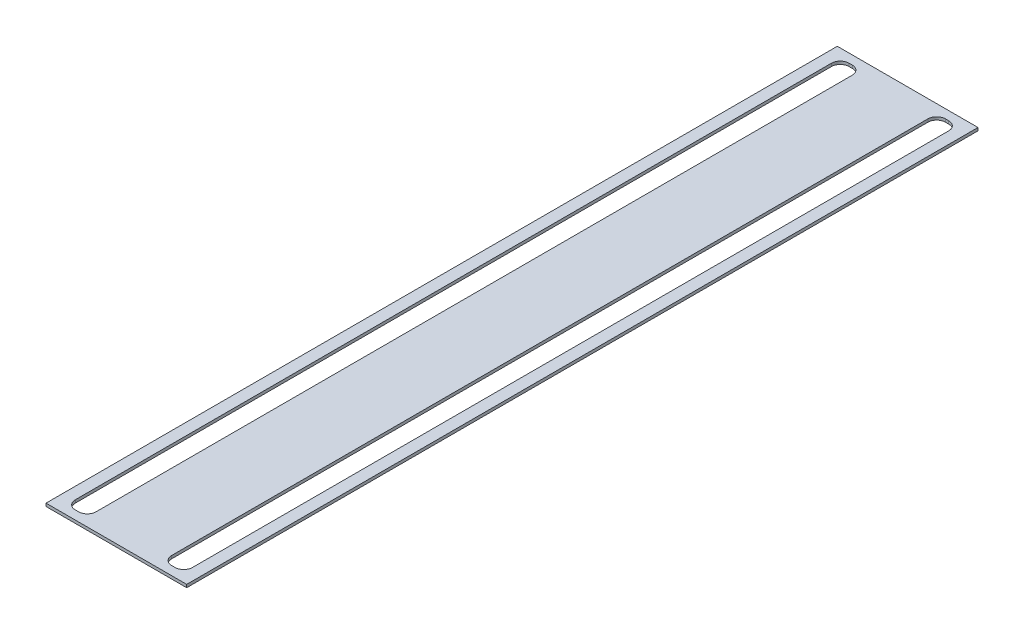
from build123d import *

# Parameters (mm, degrees)
SKETCH1_W           = 48
SKETCH1_H           = 270
SKETCH1_W_2         = 7.1
SKETCH1_H_2         = 264
BOSS_EXTRUDE1_DEPTH = 1
FILLET1_R           = 3


with BuildPart() as part:
    # Sketch1 → Boss-Extrude1 (new body)
    with BuildSketch(Plane(origin=(0, 0, 0), x_dir=(1, 0, 0), z_dir=(0, 1, 0))):
        Rectangle(SKETCH1_W, SKETCH1_H)
        with Locations((-16.45, 0)):
            Rectangle(SKETCH1_W_2, SKETCH1_H_2, mode=Mode.SUBTRACT)
        with Locations((16.45, 0)):
            Rectangle(SKETCH1_W_2, SKETCH1_H_2, mode=Mode.SUBTRACT)
    extrude(amount=BOSS_EXTRUDE1_DEPTH)

    # Fillet1
    fillet1_edges = [part.edges().sort_by_distance(p)[0] for p in [
        (-20, 0.5, -132),
        (-20, 0.5, 132),
        (-12.9, 0.5, 132),
        (-12.9, 0.5, -132),
        (20, 0.5, 132),
        (20, 0.5, -132),
        (12.9, 0.5, -132),
        (12.9, 0.5, 132),
    ]]
    fillet(fillet1_edges, radius=FILLET1_R)


solid = part.part
